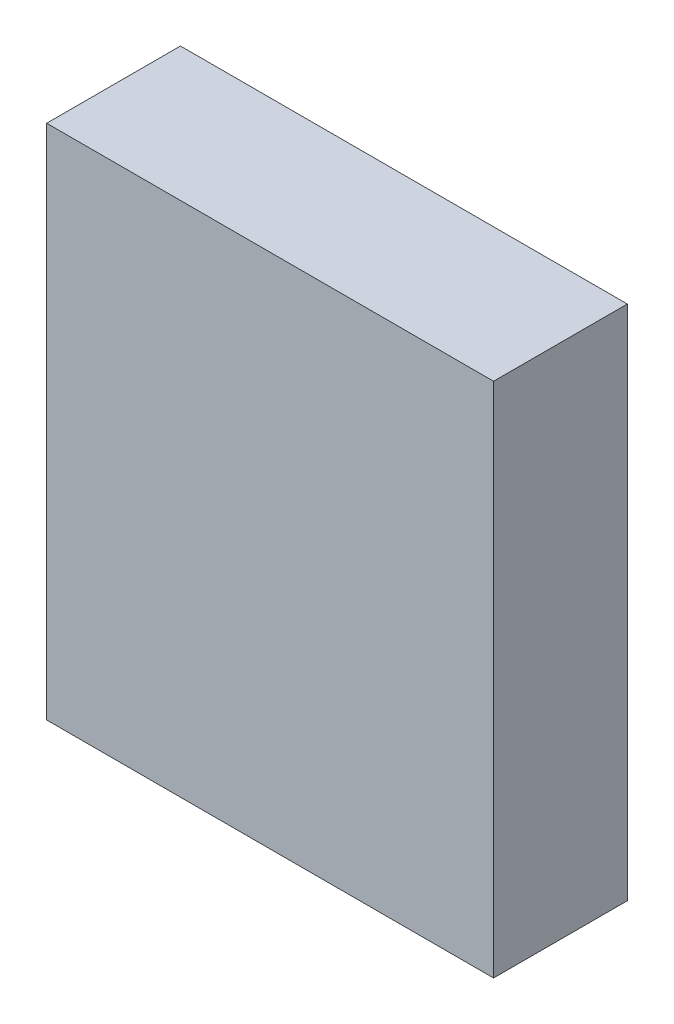
from build123d import *

# Parameters (mm, degrees)
SKETCH_1_W      = 1470
SKETCH_1_H      = 440
EXTRUDE_1_DEPTH = 1700


with BuildPart() as part:
    # 草图1 → 凸台-拉伸1 (new body)
    with BuildSketch(Plane(origin=(0, 0, 0), x_dir=(1, 0, 0), z_dir=(0, 1, 0))):
        with Locations((-735, 220)):
            Rectangle(SKETCH_1_W, SKETCH_1_H)
    extrude(amount=EXTRUDE_1_DEPTH)


solid = part.part
